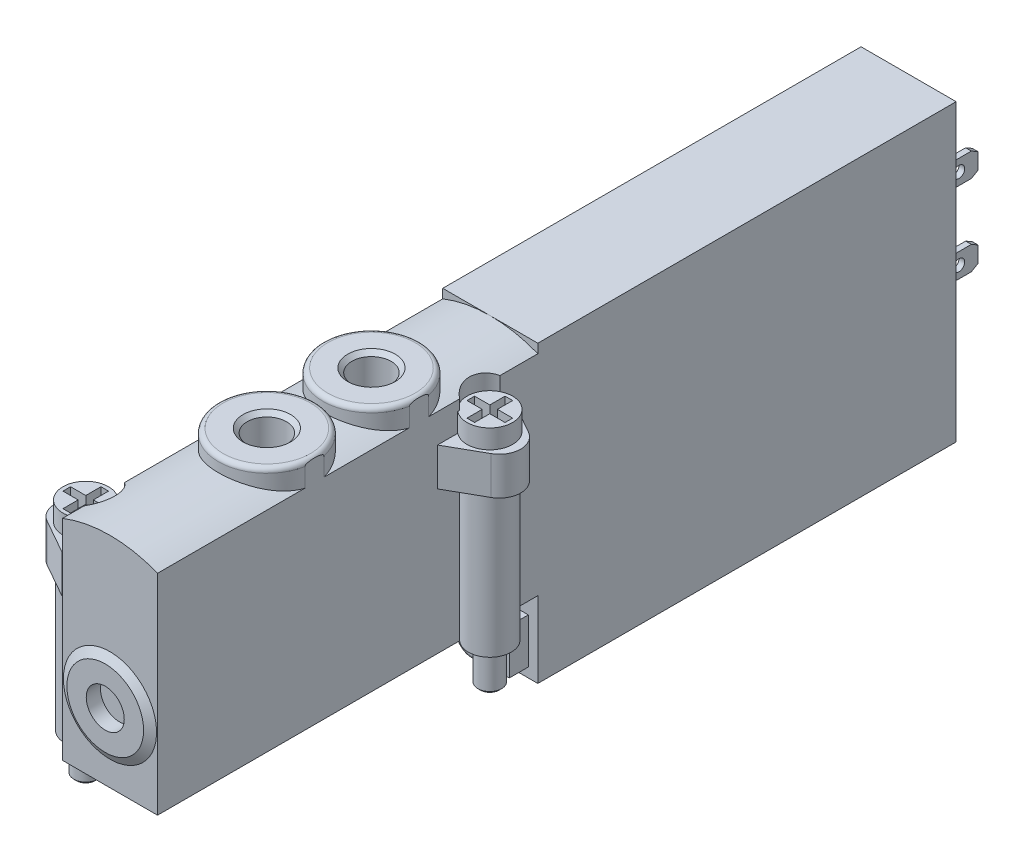
from build123d import *

# Parameters (mm, degrees)
BOSS_EXTRUDE1_DEPTH      = 5
BOSS_EXTRUDE1_DEPTH_BACK = 5
BOSS_EXTRUDE2_DEPTH      = 0.3
BOSS_EXTRUDE2_DEPTH_BACK = 0.3
SKETCH3_R                = 0.6
BOSS_EXTRUDE3_DEPTH      = 0.3
BOSS_EXTRUDE3_DEPTH_BACK = 0.3
SKETCH4_R                = 0.6
CUT_EXTRUDE1_DEPTH       = 1.5
CUT_EXTRUDE1_DEPTH_BACK  = 1.5
SKETCH6_R                = 2
BOSS_EXTRUDE4_DEPTH      = 4
BOSS_EXTRUDE5_DEPTH      = 4
SKETCH9_R                = 2.6
CUT_EXTRUDE2_DEPTH       = 5
SKETCH10_R               = 2.6
CUT_EXTRUDE3_DEPTH       = 5
CUT_EXTRUDE4_DEPTH       = 1.5
CUT_EXTRUDE5_DEPTH       = 1.5
BOSS_EXTRUDE6_DEPTH      = 2
CUT_EXTRUDE6_DEPTH       = 1.2
CUT_EXTRUDE6_DEPTH_BACK  = 1.2
CUT_EXTRUDE7_DEPTH       = 40
CUT_EXTRUDE7_DEPTH_BACK  = 40
CUT_EXTRUDE8_DEPTH       = 15
CUT_EXTRUDE8_DEPTH_BACK  = 15


with BuildPart() as part:
    # Sketch1 → Boss-Extrude1 (new, two sides: drawn at the far end of the back side and taken through both)
    with BuildSketch(Plane(origin=(0, 0, 0), x_dir=(0, 0, -1), z_dir=(1, 0, 0)).offset(-BOSS_EXTRUDE1_DEPTH_BACK)):
        Polygon((-42, 31), (-42, 8), (-2, 8), (-2, 0), (42, 0), (42, 31), align=None)
    extrude(amount=BOSS_EXTRUDE1_DEPTH + BOSS_EXTRUDE1_DEPTH_BACK)

    # Sketch2 → Revolve1 (revolve)
    with BuildSketch(Plane(origin=(0, 0, 0), x_dir=(0, 0, -1), z_dir=(1, 0, 0))):
        Polygon((42, 15.5), (42, 17.5), (44.3, 17.5), (44.5, 17.3), (44.5, 15.5), align=None)
    revolve(axis=Axis((0, 15.5, -44.5), (0, 0, 1)))

    # Sketch3 → Boss-Extrude2 (add, two sides: drawn at the far end of the back side and taken through both)
    with BuildSketch(Plane(origin=(0, 0, 0), x_dir=(0, 0, -1), z_dir=(1, 0, 0)).offset(-BOSS_EXTRUDE2_DEPTH_BACK)):
        Polygon((42, 18), (42.5, 18.5), (48.3, 18.5), (49, 18.904145188), (49, 20.595854812), (48.3, 21), (42.5, 21), (42, 21.5), align=None)
        with Locations((47, 19.75)):
            Circle(SKETCH3_R, mode=Mode.SUBTRACT)
    extrude(amount=BOSS_EXTRUDE2_DEPTH + BOSS_EXTRUDE2_DEPTH_BACK)

    # Sketch4 → Boss-Extrude3 (add, two sides: drawn at the far end of the back side and taken through both)
    with BuildSketch(Plane(origin=(0, 0, 0), x_dir=(0, 0, -1), z_dir=(1, 0, 0)).offset(-BOSS_EXTRUDE3_DEPTH_BACK)):
        Polygon((42, 13), (42, 9.5), (42.5, 10), (48.3, 10), (49, 10.404145188), (49, 12.095854812), (48.3, 12.5), (42.5, 12.5), align=None)
        with Locations((47, 11.25)):
            Circle(SKETCH4_R, mode=Mode.SUBTRACT)
    extrude(amount=BOSS_EXTRUDE3_DEPTH + BOSS_EXTRUDE3_DEPTH_BACK)

    # Sketch5 → Revolve2 (revolve)
    with BuildSketch(Plane(origin=(0, 0, 0), x_dir=(0, 0, -1), z_dir=(1, 0, 0))):
        Polygon((-42.5, 15.5), (-42.5, 19.533974596), (-42, 20.4), (-42, 15.5), align=None)
    revolve(axis=Axis((0, 15.5, 42), (0, 0, 1)))

    # Sketch6 → Cut-Extrude1 (cut, two sides: drawn at the far end of the back side and taken through both)
    with BuildSketch(Plane.XY.offset(42.5).offset(-CUT_EXTRUDE1_DEPTH_BACK)):
        with Locations((0, 15.5)):
            Circle(SKETCH6_R)
    extrude(amount=CUT_EXTRUDE1_DEPTH + CUT_EXTRUDE1_DEPTH_BACK, mode=Mode.SUBTRACT)

    # Sketch7 → Boss-Extrude4 (add)
    with BuildSketch(Plane(origin=(0, 23, 0), x_dir=(1, 0, 0), z_dir=(0, 1, 0))):
        with BuildLine():
            Line((5, -12.55), (8.608124894, -10.508203059))
            ThreePointArc((8.608124894, -10.508203059), (9.75, -8.55), (8.608124894, -6.591796941))
            Line((8.608124894, -6.591796941), (5, -4.55))
            Line((5, -4.55), (5, -12.55))
        make_face()
    extrude(amount=BOSS_EXTRUDE4_DEPTH)

    # Sketch8 → Boss-Extrude5 (add)
    with BuildSketch(Plane(origin=(0, 23, 0), x_dir=(1, 0, 0), z_dir=(0, 1, 0))):
        with BuildLine():
            Line((-8.608124894, -40.008203059), (-5, -42.05))
            Line((-5, -42.05), (-5, -34.05))
            Line((-5, -34.05), (-8.608124894, -36.091796941))
            ThreePointArc((-8.608124894, -36.091796941), (-9.75, -38.05), (-8.608124894, -40.008203059))
        make_face()
    extrude(amount=BOSS_EXTRUDE5_DEPTH)

    # Sketch9 → Cut-Extrude2 (cut)
    with BuildSketch(Plane(origin=(0, 27, 0), x_dir=(1, 0, 0), z_dir=(0, 1, 0))):
        with Locations((6.5, -8.1)):
            Circle(SKETCH9_R)
    extrude(amount=CUT_EXTRUDE2_DEPTH, mode=Mode.SUBTRACT)

    # Sketch10 → Cut-Extrude3 (cut)
    with BuildSketch(Plane(origin=(0, 27, 0), x_dir=(1, 0, 0), z_dir=(0, 1, 0))):
        with Locations((-6.5, -37.6)):
            Circle(SKETCH10_R)
    extrude(amount=CUT_EXTRUDE3_DEPTH, mode=Mode.SUBTRACT)

    # Sketch11 → Revolve3 (revolve)
    with BuildSketch(Plane(origin=(6.5, 0, 0), x_dir=(0, 0, -1), z_dir=(1, 0, 0))):
        Polygon((-8.55, 29), (-6.15, 29), (-6.15, 26.5), (-6.3, 26.5), (-6.3, 8), (-7.3, 8), (-7.3, 4.176), (-7.576, 3.9), (-8.55, 3.9), align=None)
    revolve(axis=Axis((6.5, 3.9, 8.55), (0, 1, 0)))

    # Sketch12 → Revolve4 (revolve)
    with BuildSketch(Plane(origin=(-6.5, 0, 0), x_dir=(0, 0, -1), z_dir=(1, 0, 0))):
        Polygon((-38.05, 29), (-35.65, 29), (-35.65, 26.5), (-35.8, 26.5), (-35.8, 8), (-36.8, 8), (-36.8, 4.176), (-37.076, 3.9), (-38.05, 3.9), align=None)
    revolve(axis=Axis((-6.5, 3.9, 38.05), (0, 1, 0)))

    # Sketch13 → Cut-Extrude4 (cut)
    with BuildSketch(Plane(origin=(0, 29, 0), x_dir=(1, 0, 0), z_dir=(0, 1, 0))):
        Polygon((4.5, -8.15), (4.5, -8.95), (6.1, -8.95), (6.1, -10.55), (6.9, -10.55), (6.9, -8.95), (8.5, -8.95), (8.5, -8.15), (6.9, -8.15), (6.9, -6.55), (6.1, -6.55), (6.1, -8.15), align=None)
    extrude(amount=-CUT_EXTRUDE4_DEPTH, mode=Mode.SUBTRACT)

    # Sketch14 → Cut-Extrude5 (cut)
    with BuildSketch(Plane(origin=(0, 29, 0), x_dir=(1, 0, 0), z_dir=(0, 1, 0))):
        Polygon((-8.5, -37.65), (-8.5, -38.45), (-6.9, -38.45), (-6.9, -40.05), (-6.1, -40.05), (-6.1, -38.45), (-4.5, -38.45), (-4.5, -37.65), (-6.1, -37.65), (-6.1, -36.05), (-6.9, -36.05), (-6.9, -37.65), align=None)
    extrude(amount=-CUT_EXTRUDE5_DEPTH, mode=Mode.SUBTRACT)

    # Sketch15 → Boss-Extrude6 (add)
    with BuildSketch(Plane.XY.offset(4)):
        with BuildLine():
            Line((-4, 1), (-3.5, 1))
            ThreePointArc((-3.5, 1), (-2.439339828, 1.439339828), (-2, 2.5))
            ThreePointArc((-2, 2.5), (0, 4.5), (2, 2.5))
            ThreePointArc((2, 2.5), (2.439339828, 1.439339828), (3.5, 1))
            Line((3.5, 1), (4, 1))
            Line((4, 1), (4, 5.75))
            Line((4, 5.75), (2.5, 5.75))
            Line((2.5, 5.75), (2.5, 7.95))
            Line((2.5, 7.95), (-2.5, 7.95))
            Line((-2.5, 7.95), (-2.5, 5.75))
            Line((-2.5, 5.75), (-4, 5.75))
            Line((-4, 5.75), (-4, 1))
        make_face()
    extrude(amount=-BOSS_EXTRUDE6_DEPTH)

    # Sketch16 → Revolve5 (revolve)
    with BuildSketch(Plane(origin=(0, 0, 0), x_dir=(0, 0, -1), z_dir=(1, 0, 0))):
        with BuildLine():
            Line((-4, 2.5), (-4, 4))
            ThreePointArc((-4, 4), (-3.912132034, 4.212132034), (-3.7, 4.3))
            Line((-3.7, 4.3), (-2, 4.3))
            Line((-2, 4.3), (-2, 2.5))
            Line((-2, 2.5), (-4, 2.5))
        make_face()
    revolve(axis=Axis((0, 2.5, 2), (0, 0, 1)))

    # Sketch17 → Cut-Extrude6 (cut, two sides: drawn at the far end of the back side and taken through both)
    with BuildSketch(Plane.XY.offset(4).offset(-CUT_EXTRUDE6_DEPTH_BACK)):
        Polygon((-0.75, 2.933012702), (-0.75, 2.066987298), (0, 1.633974596), (0.75, 2.066987298), (0.75, 2.933012702), (0, 3.366025404), align=None)
    extrude(amount=CUT_EXTRUDE6_DEPTH + CUT_EXTRUDE6_DEPTH_BACK, mode=Mode.SUBTRACT)

    # Sketch18 → Cut-Revolve1 (revolve, cut)
    with BuildSketch(Plane(origin=(0, 0, 0), x_dir=(0, 0, -1), z_dir=(1, 0, 0))):
        Polygon((-8.1, 8), (-10.75, 8), (-10.6, 8.15), (-10.6, 11), (-8.1, 11), align=None)
    revolve(axis=Axis((0, 11, 8.1), (0, -1, 0)), mode=Mode.SUBTRACT)

    # Sketch19 → Cut-Revolve2 (revolve, cut)
    with BuildSketch(Plane(origin=(0, 0, 0), x_dir=(0, 0, -1), z_dir=(1, 0, 0))):
        Polygon((-14.1, 8), (-16.75, 8), (-16.6, 8.15), (-16.6, 11), (-14.1, 11), align=None)
    revolve(axis=Axis((0, 11, 14.1), (0, -1, 0)), mode=Mode.SUBTRACT)

    # Sketch20 → Cut-Revolve3 (revolve, cut)
    with BuildSketch(Plane(origin=(0, 0, 0), x_dir=(0, 0, -1), z_dir=(1, 0, 0))):
        Polygon((-19.6, 8), (-22.25, 8), (-22.1, 8.15), (-22.1, 11), (-19.6, 11), align=None)
    revolve(axis=Axis((0, 11, 19.6), (0, -1, 0)), mode=Mode.SUBTRACT)

    # Sketch21 → Cut-Revolve4 (revolve, cut)
    with BuildSketch(Plane(origin=(0, 0, 0), x_dir=(0, 0, -1), z_dir=(1, 0, 0))):
        Polygon((-25.1, 8), (-27.75, 8), (-27.6, 8.15), (-27.6, 11), (-25.1, 11), align=None)
    revolve(axis=Axis((0, 11, 25.1), (0, -1, 0)), mode=Mode.SUBTRACT)

    # Sketch22 → Cut-Revolve5 (revolve, cut)
    with BuildSketch(Plane(origin=(0, 0, 0), x_dir=(0, 0, -1), z_dir=(1, 0, 0))):
        Polygon((-31.1, 8), (-33.75, 8), (-33.6, 8.15), (-33.6, 11), (-31.1, 11), align=None)
    revolve(axis=Axis((0, 11, 31.1), (0, -1, 0)), mode=Mode.SUBTRACT)

    # Sketch23 → Cut-Extrude7 (cut, two sides: drawn at the far end of the back side and taken through both)
    with BuildSketch(Plane.XY.offset(42).offset(-CUT_EXTRUDE7_DEPTH_BACK)):
        with BuildLine():
            Line((-5.1, 37.7962), (-5.1, 30))
            ThreePointArc((-5.1, 30), (0, 31), (5.1, 30))
            Line((5.1, 30), (5.1, 37.7962))
            Line((5.1, 37.7962), (-5.1, 37.7962))
        make_face()
    extrude(amount=CUT_EXTRUDE7_DEPTH + CUT_EXTRUDE7_DEPTH_BACK, mode=Mode.SUBTRACT)

    # Sketch24 → Revolve6 (revolve)
    with BuildSketch(Plane(origin=(0, 0, 0), x_dir=(0, 0, -1), z_dir=(1, 0, 0))):
        with BuildLine():
            Line((-25.5, 32.5), (-20.9, 32.5))
            ThreePointArc((-20.9, 32.5), (-20.546446609, 32.353553391), (-20.4, 32))
            Line((-20.4, 32), (-20.4, 29.5))
            Line((-20.4, 29.5), (-25.5, 29.5))
            Line((-25.5, 29.5), (-25.5, 32.5))
        make_face()
    revolve(axis=Axis((0, 29.5, 25.5), (0, 1, 0)))

    # Sketch25 → Revolve7 (revolve)
    with BuildSketch(Plane(origin=(0, 0, 0), x_dir=(0, 0, -1), z_dir=(1, 0, 0))):
        with BuildLine():
            Line((-14.5, 32.5), (-9.9, 32.5))
            ThreePointArc((-9.9, 32.5), (-9.546446609, 32.353553391), (-9.4, 32))
            Line((-9.4, 32), (-9.4, 29.5))
            Line((-9.4, 29.5), (-14.5, 29.5))
            Line((-14.5, 29.5), (-14.5, 32.5))
        make_face()
    revolve(axis=Axis((0, 29.5, 14.5), (0, 1, 0)))

    # Sketch26 → Cut-Extrude8 (cut, two sides: drawn at the far end of the back side and taken through both)
    with BuildSketch(Plane.XY.offset(20).offset(-CUT_EXTRUDE8_DEPTH_BACK)):
        Polygon((-8, 29.5), (-5, 29.5), (-5, 32.5), (5, 32.5), (5, 29.5), (8, 29.5), (8, 35.5), (-8, 35.5), align=None)
    extrude(amount=CUT_EXTRUDE8_DEPTH + CUT_EXTRUDE8_DEPTH_BACK, mode=Mode.SUBTRACT)

    # Sketch27 → Cut-Revolve6 (revolve, cut)
    with BuildSketch(Plane(origin=(0, 0, 0), x_dir=(0, 0, -1), z_dir=(1, 0, 0))):
        Polygon((-25.5, 32.5), (-23, 32.5), (-23.433, 32.067), (-23.433, 27.5), (-25.5, 27.5), align=None)
    revolve(axis=Axis((0, 27.5, 25.5), (0, 1, 0)), mode=Mode.SUBTRACT)

    # Sketch28 → Cut-Revolve7 (revolve, cut)
    with BuildSketch(Plane(origin=(0, 0, 0), x_dir=(0, 0, -1), z_dir=(1, 0, 0))):
        Polygon((-14.5, 32.5), (-12, 32.5), (-12.433, 32.067), (-12.433, 27.5), (-14.5, 27.5), align=None)
    revolve(axis=Axis((0, 27.5, 14.5), (0, 1, 0)), mode=Mode.SUBTRACT)


solid = part.part
